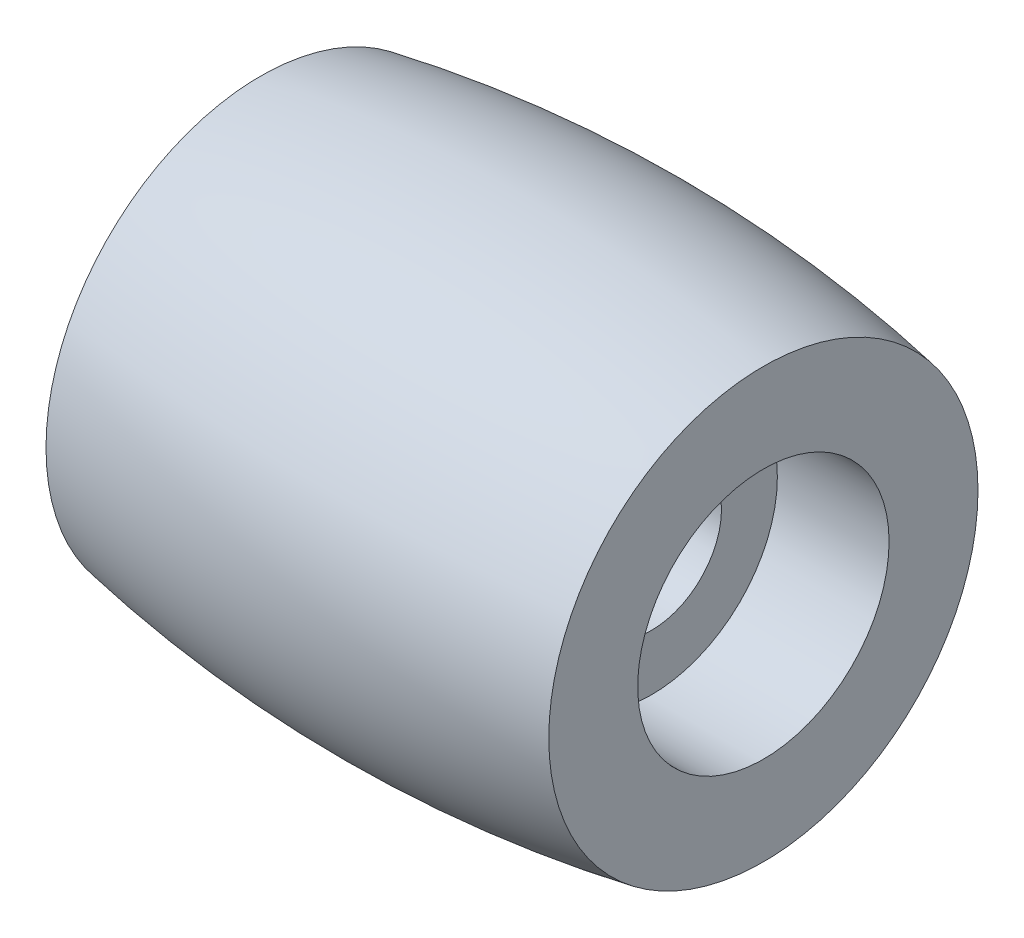
from build123d import *

# Parameters (mm, degrees)
SKETCH_2_R          = 2.5
CUT_EXTRUDE_1_DEPTH = 19.0000001
SKETCH_3_R          = 4.5
CUT_EXTRUDE_2_DEPTH = 4


with BuildPart() as part:
    # 草圖1 → 旋轉1 (revolve)
    with BuildSketch(Plane.XY):
        with BuildLine():
            Line((-9, 0), (9, 0))
            Line((9, 0), (9, 7.683330509))
            ThreePointArc((9, 7.683330509), (0, 8.5), (-9, 7.683330509))
            Line((-9, 7.683330509), (-9, 0))
        make_face()
    revolve(axis=Axis((-9, 0, 0), (1, 0, 0)))

    # 草圖2 → 除料-伸長1 (cut, through all)
    with BuildSketch(Plane(origin=(9, 0, 0), x_dir=(0, 0, -1), z_dir=(1, 0, 0))):
        Circle(SKETCH_2_R)
    extrude(amount=-CUT_EXTRUDE_1_DEPTH, mode=Mode.SUBTRACT)

    # 草圖3 → 除料-伸長2 (cut)
    with BuildSketch(Plane(origin=(9, 0, 0), x_dir=(0, 0, -1), z_dir=(1, 0, 0))):
        Circle(SKETCH_3_R)
    cut_extrude_2 = extrude(amount=-CUT_EXTRUDE_2_DEPTH, mode=Mode.SUBTRACT)

    # 鏡射1: 除料-伸長2 across plane
    add(cut_extrude_2.mirror(Plane(origin=(0, 0, 0), x_dir=(0, 0, 1), z_dir=(1, 0, 0))), mode=Mode.SUBTRACT)


solid = part.part
